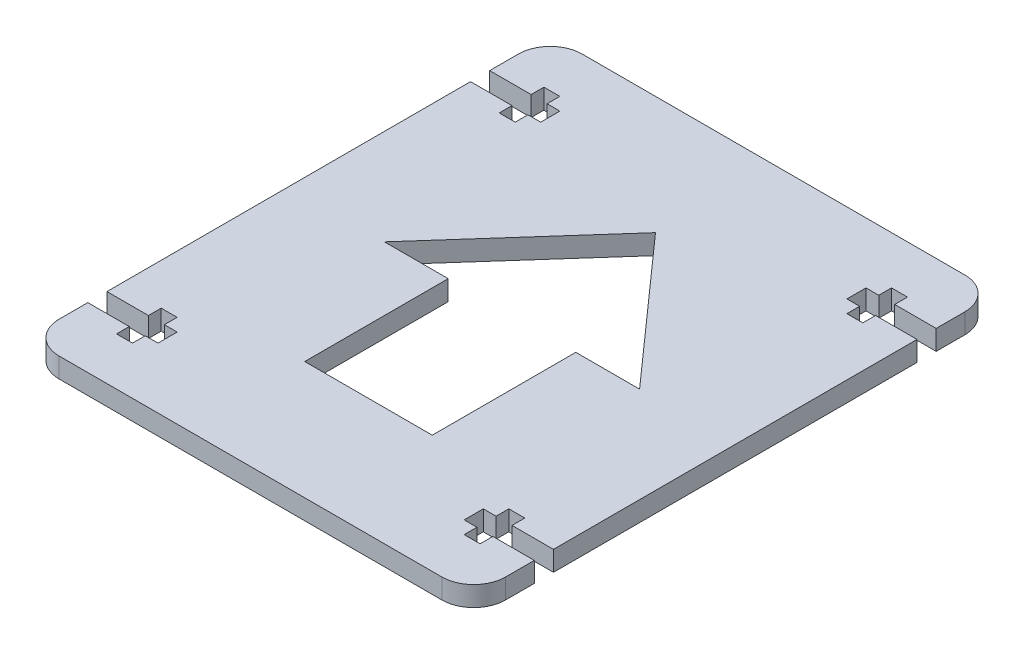
from build123d import *

# Parameters (mm, degrees)
BOSS_EXTRUDE1_DEPTH  = 1.5625
MIRROR4_COPY_1_DEPTH = 1.5625
FILLET1_R            = 5
CUT_EXTRUDE1_START   = -4.125
CUT_EXTRUDE1_DEPTH   = 5.125


with BuildPart() as part:
    # Sketch1 → Boss-Extrude1 (new body, symmetric)
    with BuildSketch(Plane(origin=(0, 0, 0), x_dir=(1, 0, 0), z_dir=(0, 1, 0))):
        Polygon((0, 41), (35, 41), (35, 31.5), (28.5, 31.5), (28.5, 33.5), (26, 33.5), (26, 31.5), (24, 31.5), (24, 28.5), (26, 28.5), (26, 26.5), (28.5, 26.5), (28.5, 28.5), (35, 28.5), (35, 0), (0, 0), align=None)
    boss_extrude1 = extrude(amount=BOSS_EXTRUDE1_DEPTH, both=True)

    # Mirror1: Boss-Extrude1 across plane
    add(boss_extrude1.mirror(Plane(origin=(0, 0, 0), x_dir=(0, 0, 1), z_dir=(1, 0, 0))))

    # Mirror4: Boss-Extrude1 across plane
    add(boss_extrude1.mirror(Plane.XY))

    # Mirror4 copy 1 sketch → Mirror4 copy 1 (add, symmetric)
    with BuildSketch(Plane(origin=(0, 0, 0), x_dir=(-1, 0, 0), z_dir=(0, 1, 0))):
        Polygon((0, 41), (35, 41), (35, 31.5), (28.5, 31.5), (28.5, 33.5), (26, 33.5), (26, 31.5), (24, 31.5), (24, 28.5), (26, 28.5), (26, 26.5), (28.5, 26.5), (28.5, 28.5), (35, 28.5), (35, 0), (0, 0), align=None)
    extrude(amount=MIRROR4_COPY_1_DEPTH, both=True)

    # Fillet1
    fillet1_edges = [part.edges().sort_by_distance(p)[0] for p in [
        (35, 0, 41),
        (35, 0, -41),
        (-35, 0, -41),
        (-35, 0, 41),
    ]]
    fillet(fillet1_edges, radius=FILLET1_R)

    # Sketch2 → Cut-Extrude1 (cut)
    with BuildSketch(Plane(origin=(0, 1.5625, 0), x_dir=(1, 0, 0), z_dir=(0, 1, 0)).offset(CUT_EXTRUDE1_START)):
        Polygon((0, 22.5), (0, -22.5), (-10, -22.5), (-10, 0), (-20, 0), align=None)
    cut_extrude1 = extrude(amount=CUT_EXTRUDE1_DEPTH, mode=Mode.SUBTRACT)

    # Mirror5: Cut-Extrude1 across plane
    add(cut_extrude1.mirror(Plane(origin=(0, 0, 0), x_dir=(0, 0, 1), z_dir=(1, 0, 0))), mode=Mode.SUBTRACT)


solid = part.part
